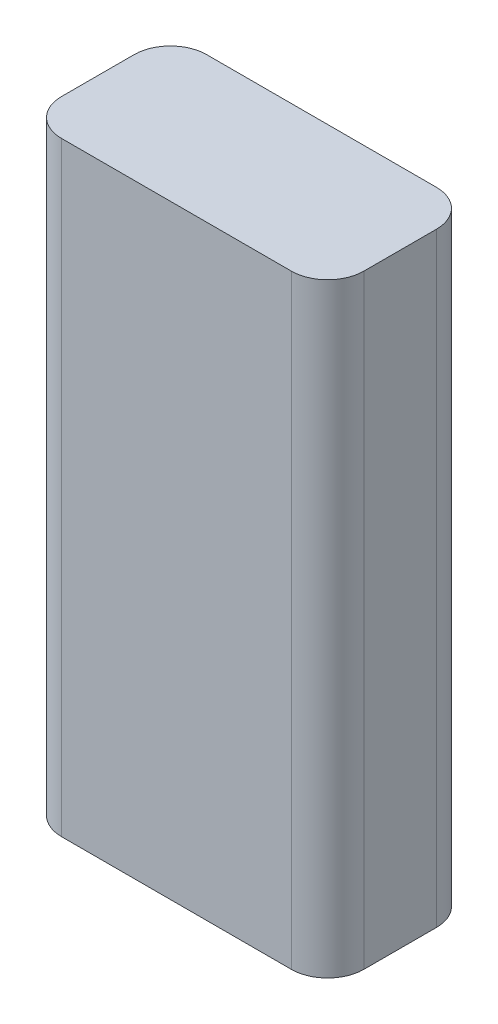
from build123d import *

# Parameters (mm, degrees)
SKIZZE1_W                       = 25
SKIZZE1_H                       = 12
AUFSATZ_LINEAR_AUSTRAGEN1_DEPTH = 50
VERRUNDUNG1_R                   = 3


with BuildPart() as part:
    # Skizze1 → Aufsatz-Linear austragen1 (new body)
    with BuildSketch(Plane(origin=(0, 0, 0), x_dir=(1, 0, 0), z_dir=(0, 1, 0))):
        with Locations((12.5, 6)):
            Rectangle(SKIZZE1_W, SKIZZE1_H)
    extrude(amount=AUFSATZ_LINEAR_AUSTRAGEN1_DEPTH)

    # Verrundung1
    verrundung1_edges = [part.edges().sort_by_distance(p)[0] for p in [
        (0, 25, -12),
        (25, 25, -12),
        (25, 25, 0),
        (0, 25, 0),
    ]]
    fillet(verrundung1_edges, radius=VERRUNDUNG1_R)


solid = part.part
